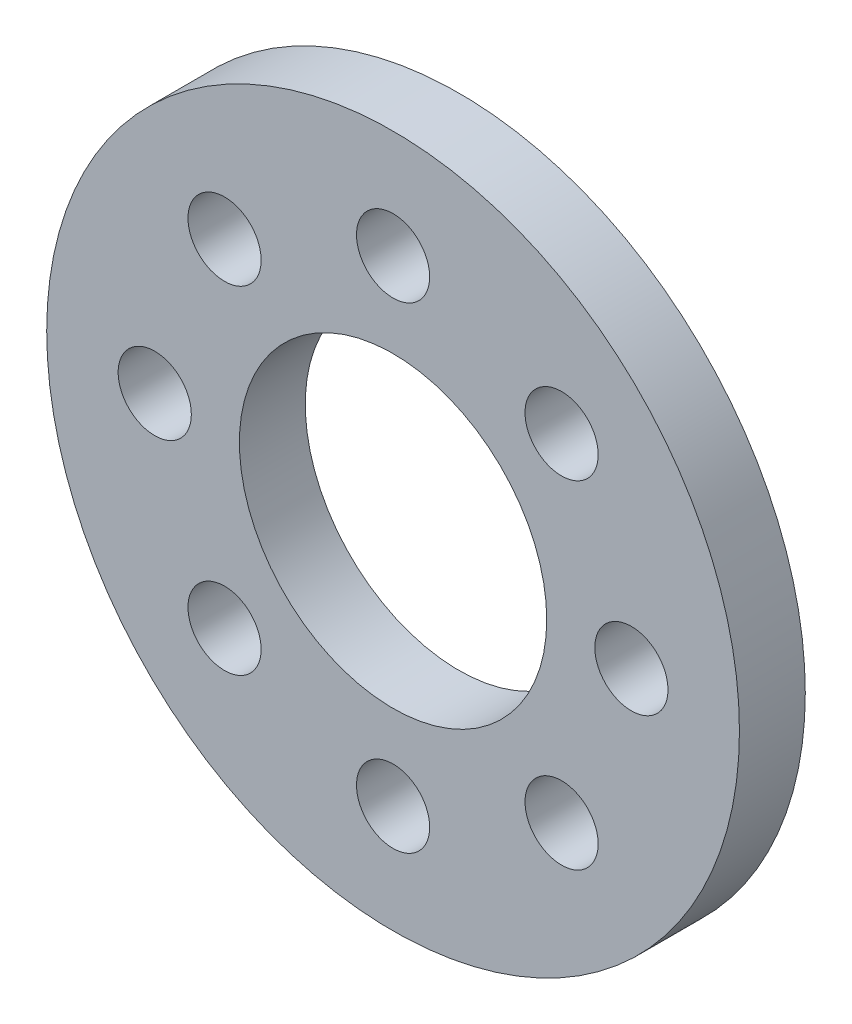
from build123d import *

# Parameters (mm, degrees)
CROQUIS1_R              = 14.2
CROQUIS1_R_2            = 6.3
CROQUIS1_R_3            = 1.5
SALIENTE_EXTRUIR1_DEPTH = 2.7


with BuildPart() as part:
    # Croquis1 → Saliente-Extruir1 (new body)
    with BuildSketch(Plane.XY):
        Circle(CROQUIS1_R)
        Circle(CROQUIS1_R_2, mode=Mode.SUBTRACT)
        with Locations((0, 9.77)):
            Circle(CROQUIS1_R_3, mode=Mode.SUBTRACT)
        with Locations((6.908433252, 6.908433252)):
            Circle(CROQUIS1_R_3, mode=Mode.SUBTRACT)
        with Locations((9.77, 0)):
            Circle(CROQUIS1_R_3, mode=Mode.SUBTRACT)
        with Locations((6.908433252, -6.908433252)):
            Circle(CROQUIS1_R_3, mode=Mode.SUBTRACT)
        with Locations((0, -9.77)):
            Circle(CROQUIS1_R_3, mode=Mode.SUBTRACT)
        with Locations((-6.908433252, -6.908433252)):
            Circle(CROQUIS1_R_3, mode=Mode.SUBTRACT)
        with Locations((-9.77, 0)):
            Circle(CROQUIS1_R_3, mode=Mode.SUBTRACT)
        with Locations((-6.908433252, 6.908433252)):
            Circle(CROQUIS1_R_3, mode=Mode.SUBTRACT)
    extrude(amount=SALIENTE_EXTRUIR1_DEPTH)


solid = part.part
